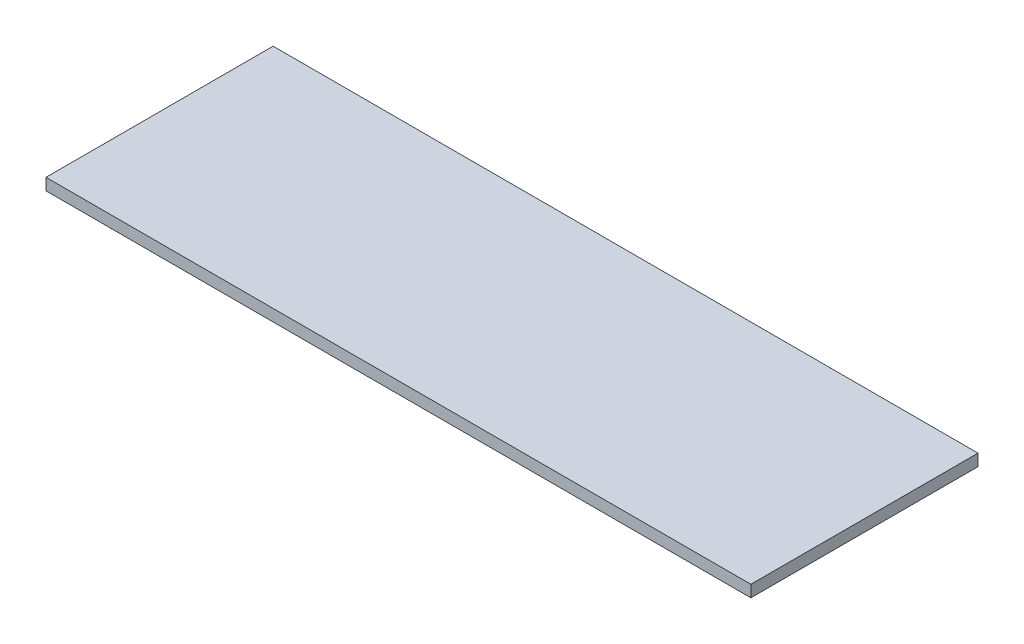
from build123d import *

# Parameters (mm, degrees)
SKETCH1_W      = 180
SKETCH1_H      = 58
EXTRUDE1_DEPTH = 3


with BuildPart() as part:
    # Sketch1 → Extrude1 (new body)
    with BuildSketch(Plane(origin=(0, 0, 0), x_dir=(1, 0, 0), z_dir=(0, 1, 0))):
        Rectangle(SKETCH1_W, SKETCH1_H)
    extrude(amount=EXTRUDE1_DEPTH)


solid = part.part
